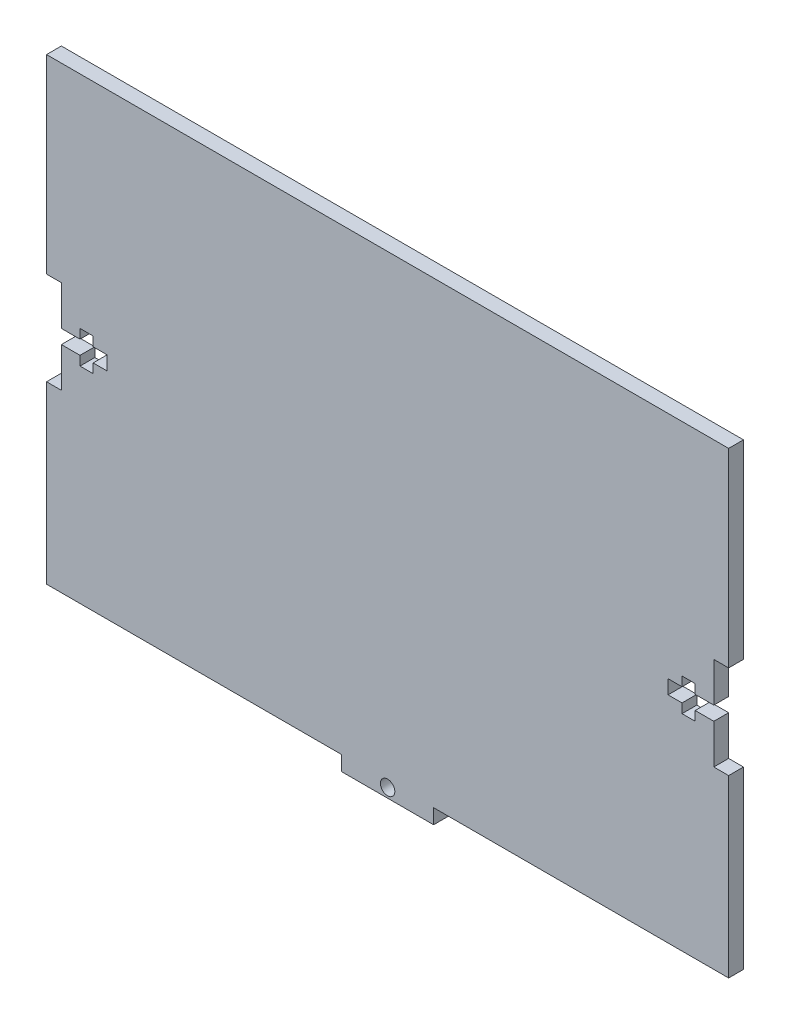
from build123d import *

# Parameters (mm, degrees)
SKETCH1_W               = 146.36
SKETCH1_H               = 101.6
BOSS_EXTRUDE1_DEPTH     = 3.18
CUT_EXTRUDE1_START      = -4.18
SKETCH2_W               = 3.18
SKETCH2_H               = 20
SKETCH2_W_2             = 13
SKETCH2_H_2             = 3
SKETCH2_W_3             = 2.82
SKETCH2_H_3             = 7
CUT_EXTRUDE1_DEPTH      = 5.18
CUT_EXTRUDE2_START      = -4.18
SKETCH3_W               = 63.305
SKETCH3_H               = 3.18
CUT_EXTRUDE2_DEPTH      = 5.18
SKETCH4_R               = 1.55
CUT_EXTRUDE3_DEPTH      = 1
CUT_EXTRUDE3_DEPTH_BACK = 4.18


with BuildPart() as part:
    # Sketch1 → Boss-Extrude1 (new body)
    with BuildSketch(Plane.XY):
        Rectangle(SKETCH1_W, SKETCH1_H)
    extrude(amount=BOSS_EXTRUDE1_DEPTH)

    # Sketch2 → Cut-Extrude1 (cut)
    with BuildSketch(Plane.XY.offset(3.18).offset(CUT_EXTRUDE1_START)):
        with Locations((-71.59, 0)):
            Rectangle(SKETCH2_W, SKETCH2_H)
        with Locations((-66.68, 0)):
            Rectangle(SKETCH2_W_2, SKETCH2_H_2)
        with Locations((-64.59, 0)):
            Rectangle(SKETCH2_W_3, SKETCH2_H_3)
    cut_extrude1 = extrude(amount=CUT_EXTRUDE1_DEPTH, mode=Mode.SUBTRACT)

    # Mirror1: Cut-Extrude1 across plane
    add(cut_extrude1.mirror(Plane(origin=(0, 0, 0), x_dir=(0, 0, 1), z_dir=(1, 0, 0))), mode=Mode.SUBTRACT)

    # Sketch3 → Cut-Extrude2 (cut)
    with BuildSketch(Plane.XY.offset(3.18).offset(CUT_EXTRUDE2_START)):
        with Locations((-41.5275, -49.21)):
            Rectangle(SKETCH3_W, SKETCH3_H)
    cut_extrude2 = extrude(amount=CUT_EXTRUDE2_DEPTH, mode=Mode.SUBTRACT)

    # Mirror2: Cut-Extrude2 across plane
    add(cut_extrude2.mirror(Plane(origin=(0, 0, 0), x_dir=(0, 0, 1), z_dir=(1, 0, 0))), mode=Mode.SUBTRACT)

    # Sketch4 → Cut-Extrude3 (cut, two sides)
    with BuildSketch(Plane.XY.offset(3.18)) as cut_extrude3_sk:
        with Locations((0, -48.8)):
            Circle(SKETCH4_R)
    extrude(amount=CUT_EXTRUDE3_DEPTH, mode=Mode.SUBTRACT)
    extrude(cut_extrude3_sk.sketch, amount=-CUT_EXTRUDE3_DEPTH_BACK, mode=Mode.SUBTRACT)


solid = part.part
